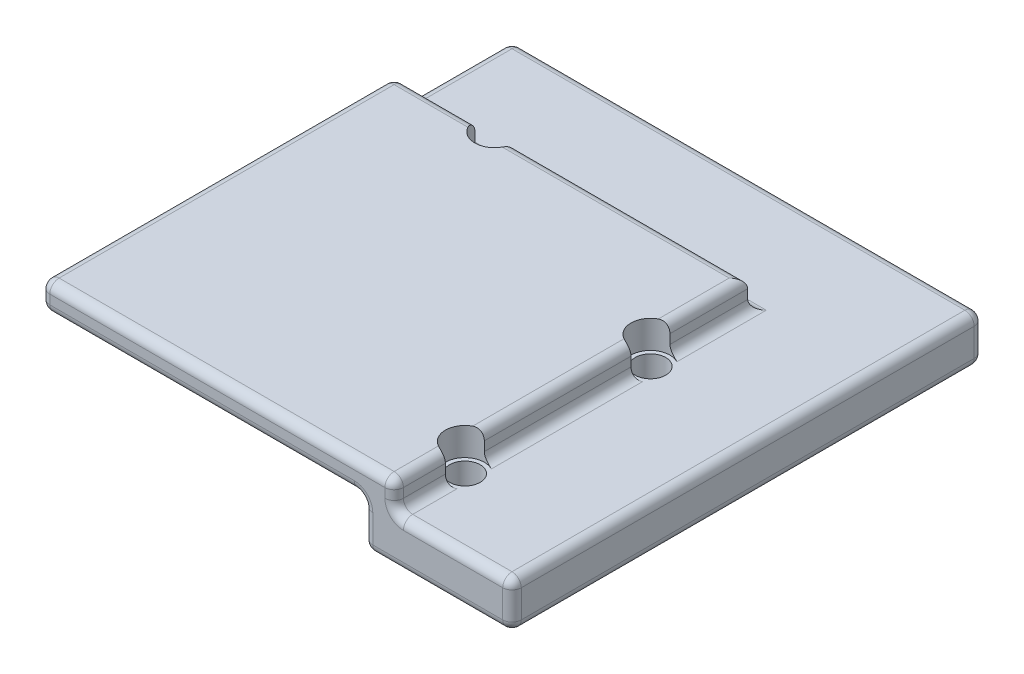
from build123d import *

# Parameters (mm, degrees)
SKETCH1_W           = 50.8
SKETCH1_H           = 8
BOSS_EXTRUDE1_DEPTH = 50.8
SKETCH2_W           = 34.8
SKETCH2_H           = 5
CUT_EXTRUDE2_DEPTH  = 34.8
CUT_EXTRUDE3_DEPTH  = 3
FILLET1_R           = 1
SKETCH4_R           = 2.1
CUT_EXTRUDE4_DEPTH  = 4
SKETCH5_R           = 1.65
CUT_EXTRUDE5_DEPTH  = 6


with BuildPart() as part:
    # Sketch1 → Boss-Extrude1 (new body)
    with BuildSketch(Plane.XY):
        Rectangle(SKETCH1_W, SKETCH1_H)
    extrude(amount=BOSS_EXTRUDE1_DEPTH)

    # Sketch2 → Cut-Extrude2 (cut)
    with BuildSketch(Plane.XY.offset(50.8)):
        with Locations((-8, -1.5)):
            Rectangle(SKETCH2_W, SKETCH2_H)
    extrude(amount=-CUT_EXTRUDE2_DEPTH, mode=Mode.SUBTRACT)

    # Sketch3 → Cut-Extrude3 (cut)
    with BuildSketch(Plane(origin=(0, 4, 0), x_dir=(1, 0, 0), z_dir=(0, 1, 0))):
        Polygon((-25.4, -12.7), (12.7, -12.7), (12.7, -50.8), (25.4, -50.8), (25.4, 0), (-25.4, 0), align=None)
    extrude(amount=-CUT_EXTRUDE3_DEPTH, mode=Mode.SUBTRACT)

    # Fillet1
    fillet1_edges = [part.edges().sort_by_distance(p)[0] for p in [
        (-25.4, 2.5, 50.8),
        (17.4, -4, 50.8),
        (-25.4, -4, 8),
        (9.4, -1.5, 50.8),
        (-8, 1, 50.8),
        (-8, -4, 16),
        (9.4, -4, 33.4),
        (9.4, -1.5, 16),
        (9.4, 1, 33.4),
        (-8, 1, 16),
        (-25.4, 1, 33.4),
        (-25.4, -1.5, 16),
        (-25.4, -1.5, 0),
        (-6.35, 4, 50.8),
        (-25.4, 2.5, 12.7),
        (12.7, 2.5, 50.8),
        (-6.35, 4, 12.7),
        (12.7, 4, 31.75),
        (-25.4, 1, 6.35),
        (0, 1, 0),
        (25.4, 1, 25.4),
        (19.05, 1, 50.8),
        (12.7, 1, 31.75),
        (-6.35, 1, 12.7),
        (25.4, -1.5, 50.8),
        (0, -4, 0),
        (25.4, -1.5, 0),
        (25.4, -4, 25.4),
        (-25.4, 4, 31.75),
    ]]
    fillet(fillet1_edges, radius=FILLET1_R)

    # Sketch4 → Cut-Extrude4 (cut, through all)
    with BuildSketch(Plane(origin=(0, 1, 0), x_dir=(1, 0, 0), z_dir=(0, 1, 0))):
        with Locations((-14.6, -12.7)):
            Circle(SKETCH4_R)
        with Locations((12.7, -43.18)):
            Circle(SKETCH4_R)
        with Locations((12.7, -23.18)):
            Circle(SKETCH4_R)
    extrude(amount=CUT_EXTRUDE4_DEPTH, mode=Mode.SUBTRACT)

    # Sketch5 → Cut-Extrude5 (cut, through all)
    with BuildSketch(Plane(origin=(0, 1, 0), x_dir=(1, 0, 0), z_dir=(0, 1, 0))):
        with Locations((-14.6, -12.7)):
            Circle(SKETCH5_R)
        with Locations((12.7, -23.18)):
            Circle(SKETCH5_R)
        with Locations((12.7, -43.18)):
            Circle(SKETCH5_R)
    extrude(amount=-CUT_EXTRUDE5_DEPTH, mode=Mode.SUBTRACT)


solid = part.part
